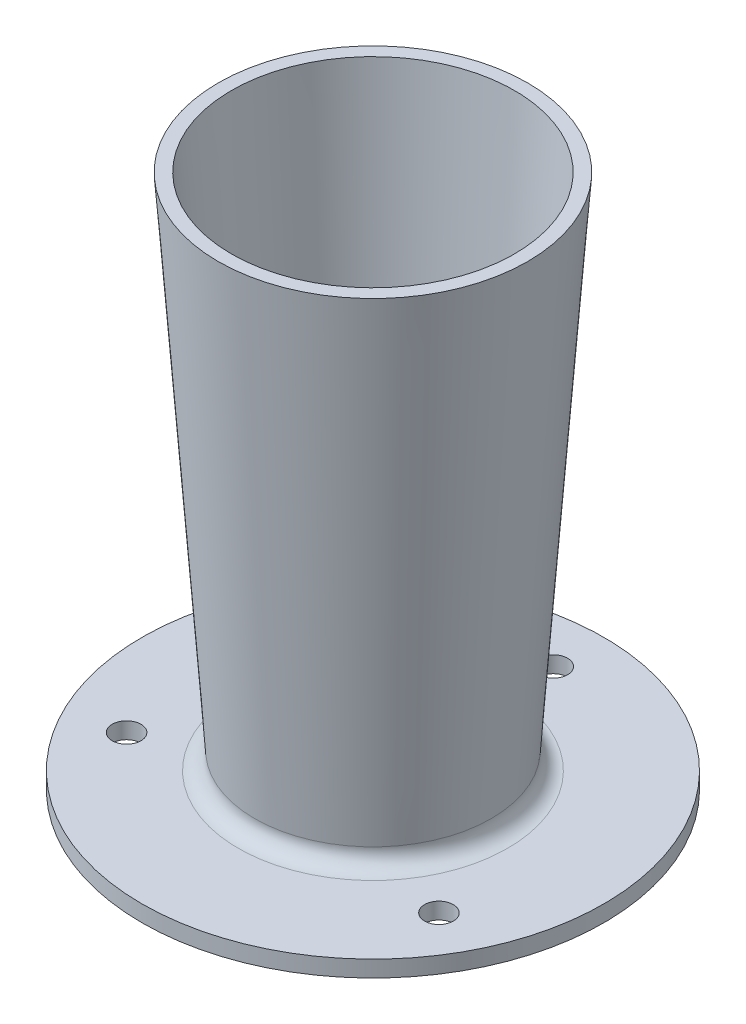
from build123d import *

# Parameters (mm, degrees)
FILLET1_R          = 2
SKETCH2_R          = 1.75
CUT_EXTRUDE1_DEPTH = 3


with BuildPart() as part:
    # Sketch1 → Revolve1 (revolve)
    with BuildSketch(Plane.XY, mode=Mode.PRIVATE) as revolve1_sk:
        Polygon((11.5, 0), (11.5, 20.222386647), (14, 20.222386647), (17.273009701, 65.222386647), (18.877236254, 65.222386647), (14.278847703, 2), (28.171211947, 2), (28.171211947, 0), align=None)
    revolve(revolve1_sk.sketch.rotate(Axis((0, 70.073472281, 0), (0, -1, 0)), 90), axis=Axis((0, 70.073472281, 0), (0, -1, 0)))  # turned: the seam where the file's is

    # Fillet1
    fillet1_edges = [part.edges().sort_by_distance(p)[0] for p in [
        (0, 2, -14.278847703),
    ]]
    fillet(fillet1_edges, radius=FILLET1_R)

    # Sketch2 → Cut-Extrude1 (cut, through all)
    with BuildSketch(Plane(origin=(0, 2, 0), x_dir=(1, 0, 0), z_dir=(0, 1, 0))):
        with Locations(Location((0, 22, 0), (0, 0, 270))):  # turned: the seam where the file's is
            Circle(SKETCH2_R)
        with Locations(Location((19.052558883, -11, 0), (0, 0, 270))):  # turned: the seam where the file's is
            Circle(SKETCH2_R)
        with Locations(Location((-19.052558883, -11, 0), (0, 0, 270))):  # turned: the seam where the file's is
            Circle(SKETCH2_R)
    extrude(amount=-CUT_EXTRUDE1_DEPTH, mode=Mode.SUBTRACT)


solid = part.part
